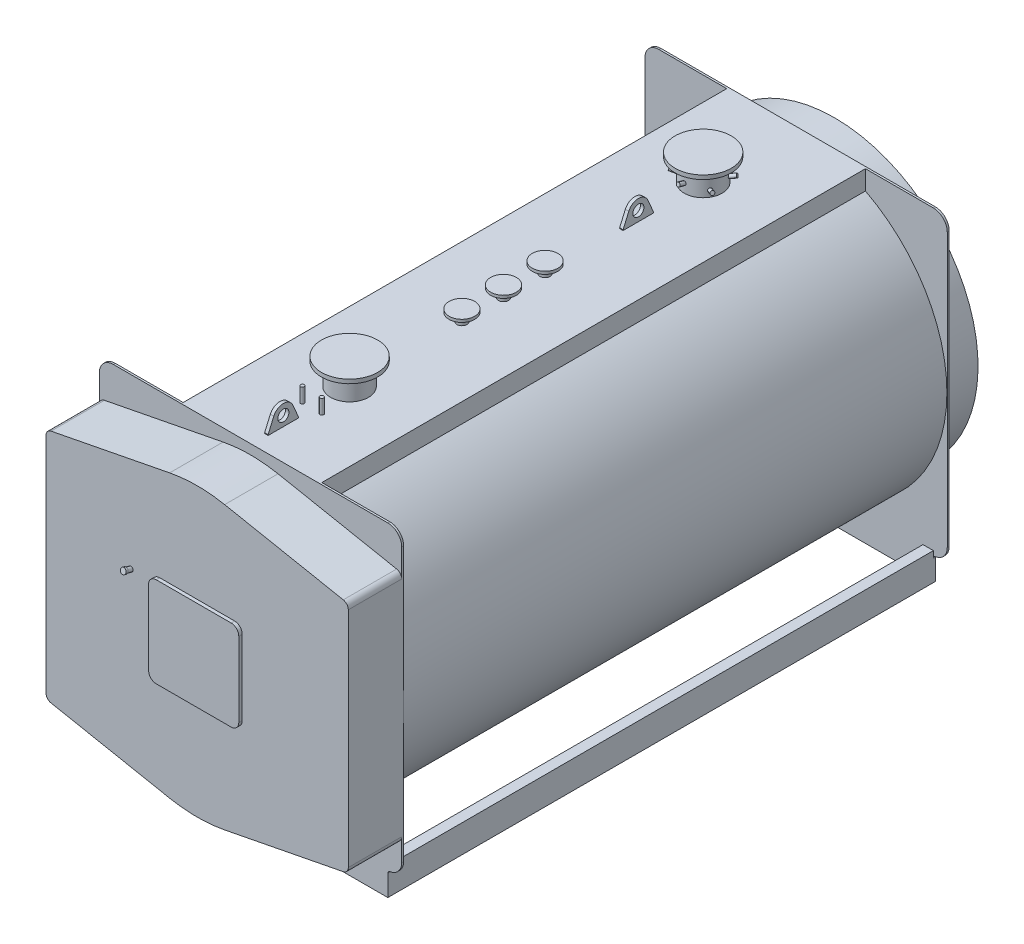
from build123d import *

# Parameters (mm, degrees)
PIASTRA_ANTERIORE_DEPTH       = 14
CORPO_DEPTH                   = 3920
PIASTRA_POSTERIORE_DEPTH      = 14
BASAMENTO_DEPTH               = 3920
SCHIZZO25_R                   = 81
ESTRUSIONE_ESTRUSIONE13_DEPTH = 8
SCHIZZO11_R                   = 21.2
SCHIZZO21_R                   = 136.55
ESTRUSIONE_ESTRUSIONE9_DEPTH  = 1294
SCHIZZO22_R                   = 202.5
ESTRUSIONE_ESTRUSIONE10_DEPTH = 29
SCHIZZO21_4_R                 = 36.5
ESTRUSIONE_ESTRUSIONE11_DEPTH = 1185
SCHIZZO35_R                   = 92.5
ESTRUSIONE_ESTRUSIONE16_DEPTH = 20
SCHIZZO21_6_R                 = 13.35
ESTRUSIONE_ESTRUSIONE18_DEPTH = 1210
RIPETIZIONECIRCOLARE1_COUNT   = 3
ESTRUSIONE_ESTRUSIONE5_DEPTH  = 385
ESTRUSIONE_ESTRUSIONE6_DEPTH  = 25
SCHIZZO37_R                   = 40
ESTRUSIONE_ESTRUSIONE17_DEPTH = 12.5


with BuildPart() as part:
    # Schizzo1 → piastra anteriore (new body)
    with BuildSketch(Plane.XY):
        with BuildLine():
            Line((-990, 2340), (990, 2340))
            ThreePointArc((990, 2340), (1060.710678119, 2310.710678119), (1090, 2240))
            Line((1090, 2240), (1090, 268.601329718))
            ThreePointArc((1090, 268.601329718), (1066.376261583, 204.051607282), (1006.666666667, 170))
            ThreePointArc((1006.666666667, 170), (994.724747683, 163.189678544), (990, 150.279734056))
            Line((990, 150.279734056), (990, 0))
            Line((990, 0), (-990, 0))
            Line((-990, 0), (-990, 150.279734056))
            ThreePointArc((-990, 150.279734056), (-994.724747683, 163.189678544), (-1006.666666667, 170))
            ThreePointArc((-1006.666666667, 170), (-1066.376261583, 204.051607282), (-1090, 268.601329718))
            Line((-1090, 268.601329718), (-1090, 2240))
            ThreePointArc((-1090, 2240), (-1060.710678119, 2310.710678119), (-990, 2340))
        make_face()
    extrude(amount=-PIASTRA_ANTERIORE_DEPTH)

    # Schizzo2 → corpo (add)
    with BuildSketch(Plane(origin=(0, 0, -14), x_dir=(-1, 0, 0), z_dir=(0, 0, -1))):
        with BuildLine():
            Line((500, 2200.741295586), (500, 2340))
            Line((500, 2340), (-500, 2340))
            Line((-500, 2340), (-500, 2200.741295586))
            ThreePointArc((-500, 2200.741295586), (0, 147.5), (500, 2200.741295586))
        make_face()
    extrude(amount=CORPO_DEPTH)

    # Schizzo3 → piastra posteriore (add)
    with BuildSketch(Plane(origin=(0, 0, -3934), x_dir=(-1, 0, 0), z_dir=(0, 0, -1))):
        with BuildLine():
            Line((-990, 150.279734056), (-990, 0))
            Line((-990, 0), (990, 0))
            Line((990, 0), (990, 150.279734056))
            ThreePointArc((990, 150.279734056), (994.724747683, 163.189678544), (1006.666666667, 170))
            ThreePointArc((1006.666666667, 170), (1066.376261583, 204.051607282), (1090, 268.601329718))
            Line((1090, 268.601329718), (1090, 2240))
            ThreePointArc((1090, 2240), (1060.710678119, 2310.710678119), (990, 2340))
            Line((990, 2340), (-990, 2340))
            ThreePointArc((-990, 2340), (-1060.710678119, 2310.710678119), (-1090, 2240))
            Line((-1090, 2240), (-1090, 268.601329718))
            ThreePointArc((-1090, 268.601329718), (-1066.376261583, 204.051607282), (-1006.666666667, 170))
            ThreePointArc((-1006.666666667, 170), (-994.724747683, 163.189678544), (-990, 150.279734056))
        make_face()
    extrude(amount=PIASTRA_POSTERIORE_DEPTH)

    # Schizzo4 → basamento (add)
    with BuildSketch(Plane(origin=(0, 0, -14), x_dir=(-1, 0, 0), z_dir=(0, 0, -1))):
        Polygon((-915, 0), (-990, 0), (-990, 200), (-915, 200), (-915, 192), (-982, 192), (-982, 8), (-915, 8), align=None)
    extrude(amount=BASAMENTO_DEPTH)

    # Schizzo23 → camera-fumo (revolve)
    with BuildSketch(Plane(origin=(0, 0, 0), x_dir=(0, 0, -1), z_dir=(1, 0, 0))):
        Polygon((3948, 2270), (4211, 2270), (4211, 1559), (4256, 1559), (4256, 1600), (4261, 1600), (4261, 1554), (4206, 1554), (4206, 2265), (3948, 2265), align=None)
    revolve(axis=Axis((0, 1235, -4219.232253574), (0, 0, 1)))

    # Schizzo25 → Estrusione-Estrusione13 (add)
    with BuildSketch(Plane(origin=(0, 0, -4211), x_dir=(-1, 0, 0), z_dir=(0, 0, -1))):
        with Locations(Location((0, 394.5, 0), (0, 0, 270))):  # turned: the seam where the file's is
            Circle(SCHIZZO25_R)
    extrude(amount=ESTRUSIONE_ESTRUSIONE13_DEPTH)

    # Sweep1: sweep along a path in Schizzo10
    with BuildLine(Plane(origin=(0, 0, 0), x_dir=(0, 0, -1), z_dir=(1, 0, 0))) as sweep1_path:
        Line((3804, 410), (3804, 210))
        ThreePointArc((3804, 210), (3821.573593129, 167.573593129), (3864, 150))
        Line((3864, 150), (4259, 150))
    # Schizzo11 → Sweep1 (sweep)
    with BuildSketch(Plane(origin=(0, 150, -4259), x_dir=(-1, 0, 0), z_dir=(0, 0, -1))):
        Circle(SCHIZZO11_R)
    sweep(path=sweep1_path.line)

    # Schizzo21 → Estrusione-Estrusione9 (add)
    with BuildSketch(Plane(origin=(0, 1235, 0), x_dir=(1, 0, 0), z_dir=(0, 1, 0))):
        with Locations(Location((0, 714, 0), (0, 0, 180))):  # turned: the seam where the file's is
            Circle(SCHIZZO21_R)
        with Locations(Location((0, 3264, 0), (0, 0, 180))):  # turned: the seam where the file's is
            Circle(SCHIZZO21_R)
    extrude(amount=ESTRUSIONE_ESTRUSIONE9_DEPTH)

    # Schizzo22 → Estrusione-Estrusione10 (add)
    with BuildSketch(Plane(origin=(0, 2529, 0), x_dir=(1, 0, 0), z_dir=(0, 1, 0))):
        with Locations(Location((0, 714, 0), (0, 0, 270))):  # turned: the seam where the file's is
            Circle(SCHIZZO22_R)
        with Locations(Location((0, 3264, 0), (0, 0, 270))):  # turned: the seam where the file's is
            Circle(SCHIZZO22_R)
    extrude(amount=-ESTRUSIONE_ESTRUSIONE10_DEPTH)

    # Schizzo21_4 → Estrusione-Estrusione11 (add)
    with BuildSketch(Plane(origin=(0, 1235, 0), x_dir=(1, 0, 0), z_dir=(0, 1, 0))):
        with Locations(Location((0, 2124, 0), (0, 0, 180))):  # turned: the seam where the file's is
            Circle(SCHIZZO21_4_R)
        with Locations(Location((0, 1524, 0), (0, 0, 180))):  # turned: the seam where the file's is
            Circle(SCHIZZO21_4_R)
        with Locations(Location((0, 1824, 0), (0, 0, 180))):  # turned: the seam where the file's is
            Circle(SCHIZZO21_4_R)
    extrude(amount=ESTRUSIONE_ESTRUSIONE11_DEPTH)

    # Schizzo35 → Estrusione-Estrusione16 (add)
    with BuildSketch(Plane(origin=(0, 2420, 0), x_dir=(1, 0, 0), z_dir=(0, 1, 0))):
        with Locations(Location((0, 1524, 0), (0, 0, 270))):  # turned: the seam where the file's is
            Circle(SCHIZZO35_R)
        with Locations(Location((0, 1824, 0), (0, 0, 270))):  # turned: the seam where the file's is
            Circle(SCHIZZO35_R)
        with Locations(Location((0, 2124, 0), (0, 0, 270))):  # turned: the seam where the file's is
            Circle(SCHIZZO35_R)
    extrude(amount=-ESTRUSIONE_ESTRUSIONE16_DEPTH)

    # Schizzo21_6 → Estrusione-Estrusione18 (add)
    with BuildSketch(Plane(origin=(0, 1235, 0), x_dir=(1, 0, 0), z_dir=(0, 1, 0))):
        with Locations(Location((-70, 444, 0), (0, 0, 180))):  # turned: the seam where the file's is
            Circle(SCHIZZO21_6_R)
        with Locations(Location((70, 444, 0), (0, 0, 180))):  # turned: the seam where the file's is
            Circle(SCHIZZO21_6_R)
    extrude(amount=ESTRUSIONE_ESTRUSIONE18_DEPTH)

    # Schizzo9 → Rivoluzione3 (revolve)
    with BuildSketch(Plane(origin=(0, 0, 0), x_dir=(0, 0, -1), z_dir=(1, 0, 0))):
        Polygon((3382.55, 2393.101379163), (3440.505549577, 2408.630521869), (3443.986665734, 2395.638819505), (3386.031116157, 2380.109676799), align=None)
    rivoluzione3 = revolve(axis=Axis((0, 2384, -3400.55), (0, -0.258819045, 0.965925826)))

    # Schizzo34 → Rivoluzione5 (revolve)
    with BuildSketch(Plane(origin=(0, 0, 0), x_dir=(0, 0, -1), z_dir=(1, 0, 0))):
        Polygon((3087.494450423, 2428.630521869), (3145.45, 2413.101379163), (3141.968883843, 2400.109676799), (3084.013334266, 2415.638819505), align=None)
    rivoluzione5 = revolve(axis=Axis((0, 2404, -3127.45), (0, 0.258819045, 0.965925826)))

    # RipetizioneCircolare1: Rivoluzione3, Rivoluzione5 ×3 about axis
    ripetizionecircolare1_axis = Axis((0, 0, -3264), (0, 1, 0))
    add([rivoluzione3.rotate(ripetizionecircolare1_axis, i * 360 / RIPETIZIONECIRCOLARE1_COUNT) for i in range(1, RIPETIZIONECIRCOLARE1_COUNT)])
    add([rivoluzione5.rotate(ripetizionecircolare1_axis, i * 360 / RIPETIZIONECIRCOLARE1_COUNT) for i in range(1, RIPETIZIONECIRCOLARE1_COUNT)])

    # Schizzo33 → Rivoluzione4 (revolve)
    with BuildSketch(Plane(origin=(0, 0, 0), x_dir=(0, 0, -1), z_dir=(1, 0, 0))):
        Polygon((832.55, 2413.101379163), (890.505549577, 2428.630521869), (893.986665734, 2415.638819505), (836.031116157, 2400.109676799), align=None)
    revolve(axis=Axis((0, 2428.927708421, -943.581474343), (0, -0.258819045, 0.965925826)))

    # Schizzo14 → Estrusione-Estrusione5 (add)
    with BuildSketch(Plane.XY):
        with BuildLine():
            Line((-1090, 2039.75), (-1090, 430.25))
            ThreePointArc((-1090, 430.25), (-1079.733611394, 401.639228609), (-1053.618833797, 386.08309266))
            Line((-1053.618833797, 386.08309266), (-198.233177338, 219.161131182))
            ThreePointArc((-198.233177338, 219.161131182), (0, 200), (198.233177338, 219.161131182))
            Line((198.233177338, 219.161131182), (1053.618833797, 386.08309266))
            ThreePointArc((1053.618833797, 386.08309266), (1079.733611394, 401.639228609), (1090, 430.25))
            Line((1090, 430.25), (1090, 2039.75))
            ThreePointArc((1090, 2039.75), (1079.733611394, 2068.360771391), (1053.618833797, 2083.91690734))
            Line((1053.618833797, 2083.91690734), (198.233177338, 2250.838868818))
            ThreePointArc((198.233177338, 2250.838868818), (0, 2270), (-198.233177338, 2250.838868818))
            Line((-198.233177338, 2250.838868818), (-1053.618833797, 2083.91690734))
            ThreePointArc((-1053.618833797, 2083.91690734), (-1079.733611394, 2068.360771391), (-1090, 2039.75))
        make_face()
    extrude(amount=ESTRUSIONE_ESTRUSIONE5_DEPTH)

    # Schizzo15 → Estrusione-Estrusione6 (add)
    with BuildSketch(Plane.XY.offset(385)):
        with BuildLine():
            Line((-270, 1560), (270, 1560))
            ThreePointArc((270, 1560), (308.890872965, 1543.890872965), (325, 1505))
            Line((325, 1505), (325, 965))
            ThreePointArc((325, 965), (308.890872965, 926.109127035), (270, 910))
            Line((270, 910), (-270, 910))
            ThreePointArc((-270, 910), (-308.890872965, 926.109127035), (-325, 965))
            Line((-325, 965), (-325, 1505))
            ThreePointArc((-325, 1505), (-308.890872965, 1543.890872965), (-270, 1560))
        make_face()
    extrude(amount=ESTRUSIONE_ESTRUSIONE6_DEPTH)

    # Schizzo18 → Rivoluzione2 (revolve)
    with BuildSketch(Plane(origin=(-478, 0, 0), x_dir=(0, 0, -1), z_dir=(1, 0, 0))):
        Polygon((-420.241857968, 1537.687431022), (-419.426577976, 1540.730097375), (-434.881391196, 1544.871202097), (-440.057772098, 1525.552685571), (-365, 1505.441016151), (-360.63889909, 1521.716866324), align=None)
    revolve(axis=Axis((-478, 1510.8, 385), (0, 0.258819045, 0.965925826)))

    # Schizzo37 → Estrusione-Estrusione17 (add, symmetric)
    with BuildSketch(Plane(origin=(0, 0, 0), x_dir=(0, 0, -1), z_dir=(1, 0, 0))):
        with BuildLine():
            Line((114, 2265), (114, 2345))
            Line((114, 2345), (155.208335614, 2439.878201268))
            ThreePointArc((155.208335614, 2439.878201268), (224, 2485), (292.791664386, 2439.878201268))
            Line((292.791664386, 2439.878201268), (334, 2345))
            Line((334, 2345), (334, 2265))
            Line((334, 2265), (114, 2265))
        make_face()
        with Locations((224, 2410)):
            Circle(SCHIZZO37_R, mode=Mode.SUBTRACT)
        with BuildLine():
            Line((2674, 2265), (2674, 2345))
            Line((2674, 2345), (2715.208335614, 2439.878201268))
            ThreePointArc((2715.208335614, 2439.878201268), (2784, 2485), (2852.791664386, 2439.878201268))
            Line((2852.791664386, 2439.878201268), (2894, 2345))
            Line((2894, 2345), (2894, 2265))
            Line((2894, 2265), (2674, 2265))
        make_face()
        with Locations((2784, 2410)):
            Circle(SCHIZZO37_R, mode=Mode.SUBTRACT)
    extrude(amount=ESTRUSIONE_ESTRUSIONE17_DEPTH, both=True)


solid = part.part
